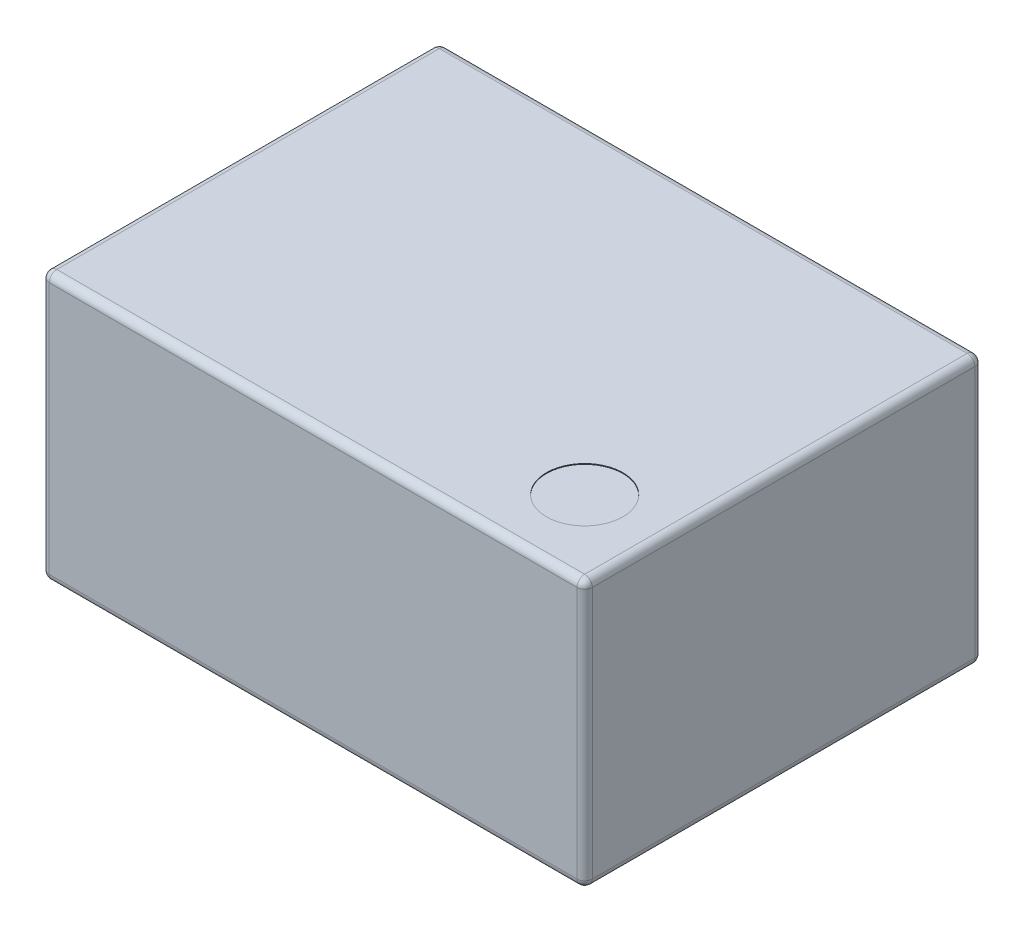
from build123d import *

# Parameters (mm, degrees)
SKETCH1_W           = 7.1
SKETCH1_H           = 5.2
BOSS_EXTRUDE1_DEPTH = 3.5
FILLET1_R           = 0.1
SKETCH2_R           = 0.5
CUT_EXTRUDE1_DEPTH  = 0.01


with BuildPart() as part:
    # Sketch1 → Boss-Extrude1 (new body)
    with BuildSketch(Plane(origin=(0, 0, 0), x_dir=(1, 0, 0), z_dir=(0, 1, 0))):
        Rectangle(SKETCH1_W, SKETCH1_H)
    extrude(amount=BOSS_EXTRUDE1_DEPTH)

    # Fillet1
    fillet1_edges = [part.edges().sort_by_distance(p)[0] for p in [
        (-3.55, 3.5, 0),
        (0, 3.5, 2.6),
        (3.55, 3.5, 0),
        (0, 0, 2.6),
        (-3.55, 0, 0),
        (0, 0, -2.6),
        (3.55, 0, 0),
        (0, 3.5, -2.6),
        (3.55, 1.75, 2.6),
        (-3.55, 1.75, 2.6),
        (-3.55, 1.75, -2.6),
        (3.55, 1.75, -2.6),
    ]]
    fillet(fillet1_edges, radius=FILLET1_R)

    # Sketch2 → Cut-Extrude1 (cut)
    with BuildSketch(Plane(origin=(0, 3.5, 0), x_dir=(1, 0, 0), z_dir=(0, 1, 0))):
        with Locations((2.55, -1.6)):
            Circle(SKETCH2_R)
    extrude(amount=-CUT_EXTRUDE1_DEPTH, mode=Mode.SUBTRACT)


solid = part.part
